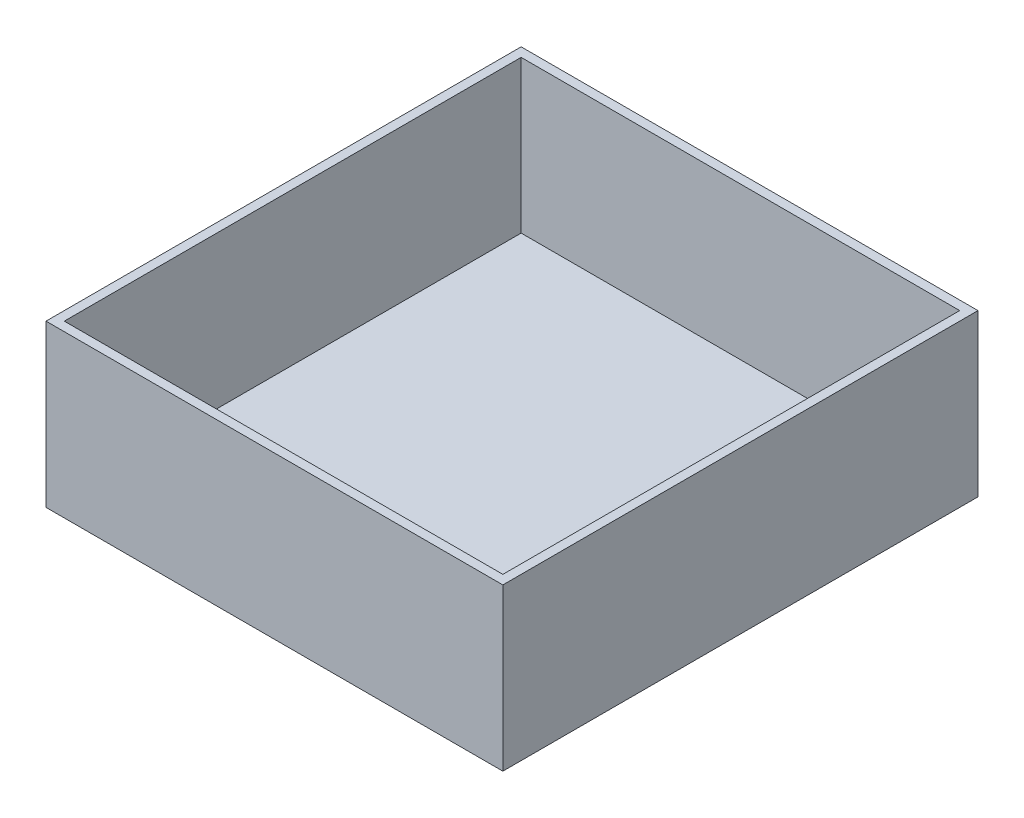
from build123d import *

# Parameters (mm, degrees)
SKETCH1_W           = 158.75
SKETCH1_H           = 165.1
BOSS_EXTRUDE1_DEPTH = 3.175
SKETCH2_W           = 158.75
SKETCH2_H           = 165.1
SKETCH2_W_2         = 152.4
SKETCH2_H_2         = 158.75
BOSS_EXTRUDE2_DEPTH = 52.8828


with BuildPart() as part:
    # Sketch1 → Boss-Extrude1 (new body)
    with BuildSketch(Plane(origin=(0, 0, 0), x_dir=(1, 0, 0), z_dir=(0, 1, 0))):
        Rectangle(SKETCH1_W, SKETCH1_H)
    extrude(amount=BOSS_EXTRUDE1_DEPTH)

    # Sketch2 → Boss-Extrude2 (add)
    with BuildSketch(Plane(origin=(0, 3.175, 0), x_dir=(1, 0, 0), z_dir=(0, 1, 0))):
        Rectangle(SKETCH2_W, SKETCH2_H)
        Rectangle(SKETCH2_W_2, SKETCH2_H_2, mode=Mode.SUBTRACT)
    extrude(amount=BOSS_EXTRUDE2_DEPTH)


solid = part.part
